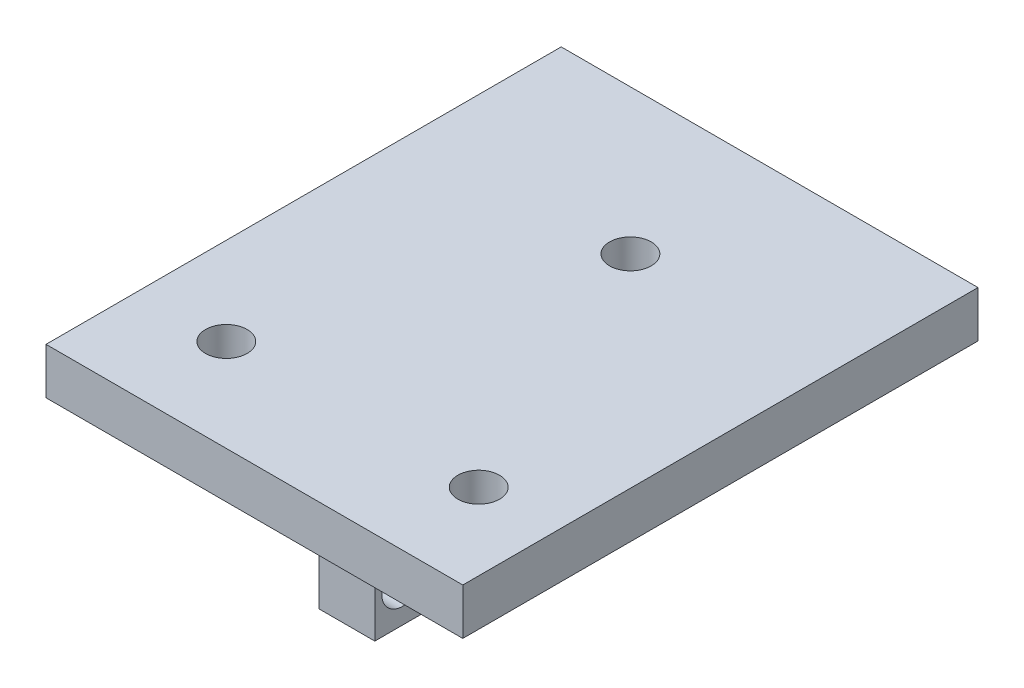
from build123d import *

# Parameters (mm, degrees)
BOSS_EXTRUDE1_DEPTH       = 5
F_8_CLEARANCE_HOLE1_D     = 4.4958
F_8_CLEARANCE_HOLE1_DEPTH = 17
F_8_CLEARANCE_HOLE1_TIP   = 1.350674586
SKETCH3_W                 = 6
SKETCH3_H                 = 6
BOSS_EXTRUDE2_DEPTH       = 15
F_8_CLEARANCE_HOLE2_D     = 4.4958
F_8_CLEARANCE_HOLE2_DEPTH = 17
F_8_CLEARANCE_HOLE2_TIP   = 1.350674586


with BuildPart() as part:
    # Sketch1 → Boss-Extrude1 (new body)
    with BuildSketch(Plane(origin=(0, 0, 0), x_dir=(1, 0, 0), z_dir=(0, 1, 0))):
        Polygon((-14.338976611, 0), (30.661023389, 0), (30.661023389, 55.621488653), (8.161023389, 55.621488653), (-14.338976611, 55.621488653), align=None)
    extrude(amount=BOSS_EXTRUDE1_DEPTH)

    # #8 Clearance Hole1
    with Locations(Plane(origin=(22.377803879, 0, -10), x_dir=(0, 0, -1), z_dir=(0, -1, 0))):
        with Locations((0, 0), (0, -27.25), (30.001031232, -13.625)):
            Hole(F_8_CLEARANCE_HOLE1_D / 2, depth=F_8_CLEARANCE_HOLE1_DEPTH)
            with Locations((0, 0, -(F_8_CLEARANCE_HOLE1_DEPTH + F_8_CLEARANCE_HOLE1_TIP / 2))):  # 118° drill point
                Cone(0, F_8_CLEARANCE_HOLE1_D / 2, F_8_CLEARANCE_HOLE1_TIP, mode=Mode.SUBTRACT)

    # Sketch3 → Boss-Extrude2 (add)
    with BuildSketch(Plane(origin=(0, 0, 0), x_dir=(-1, 0, 0), z_dir=(0, -1, 0))):
        with Locations((-8.161023389, 47.5)):
            Rectangle(SKETCH3_W, SKETCH3_H)
        with Locations((-8.161023389, 13)):
            Rectangle(SKETCH3_W, SKETCH3_H)
    extrude(amount=BOSS_EXTRUDE2_DEPTH)

    # #8 Clearance Hole2
    with Locations(Plane(origin=(5.161023389, -11, -47.5), x_dir=(0, 0, -1), z_dir=(-1, 0, 0))):
        with Locations((0, 0), (-34.5, 0)):
            Hole(F_8_CLEARANCE_HOLE2_D / 2, depth=F_8_CLEARANCE_HOLE2_DEPTH)
            with Locations((0, 0, -(F_8_CLEARANCE_HOLE2_DEPTH + F_8_CLEARANCE_HOLE2_TIP / 2))):  # 118° drill point
                Cone(0, F_8_CLEARANCE_HOLE2_D / 2, F_8_CLEARANCE_HOLE2_TIP, mode=Mode.SUBTRACT)


solid = part.part
